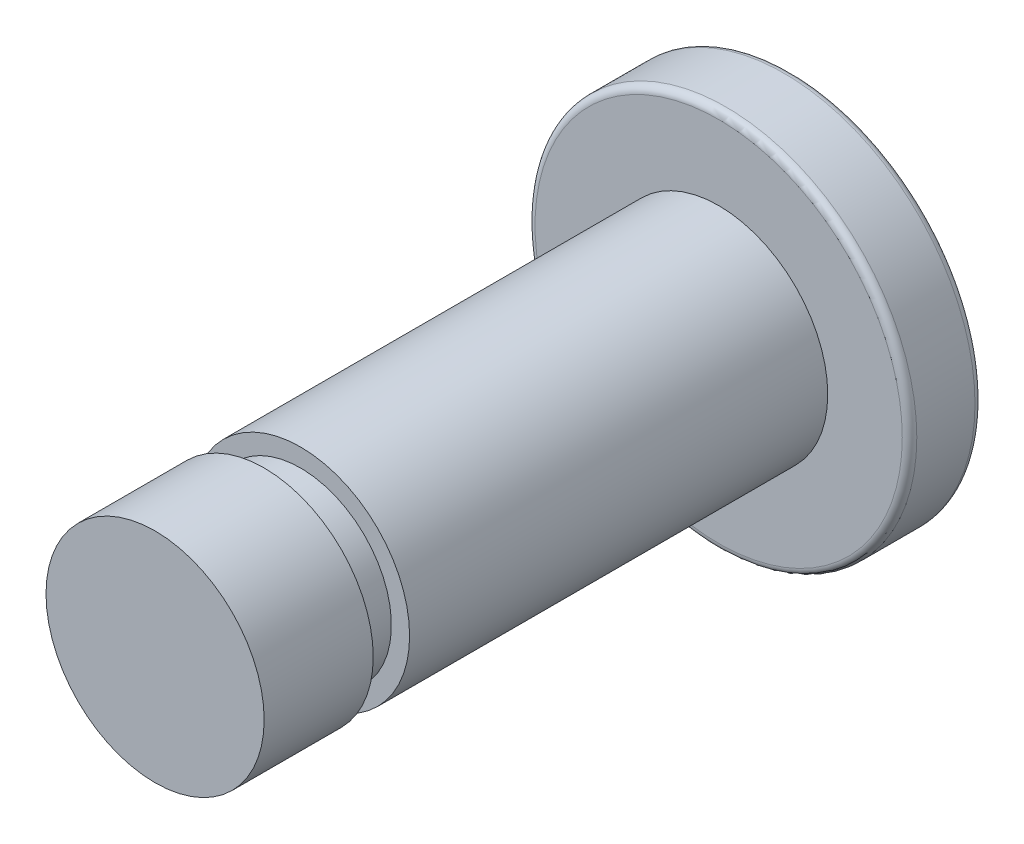
from build123d import *

# Parameters (mm, degrees)
REDONDEO1_R = 0.2


with BuildPart() as part:
    # Croquis2 → Revolución1 (revolve)
    with BuildSketch(Plane(origin=(0, 0, 0), x_dir=(1, 0, 0), z_dir=(0, 1, 0))):
        Polygon((0, 0), (0, 3), (0.5, 3), (0.5, 4), (0, 4), (0, 15.5), (-2.25, 15.5), (-2.25, 17.5), (3, 17.5), (3, 0), align=None)
    revolve(axis=Axis((3, 0, -17.5), (0, 0, 1)))

    # Redondeo1
    redondeo1_edges = [part.edges().sort_by_distance(p)[0] for p in [
        (8.25, 0, -17.5),
        (8.25, 0, -15.5),
    ]]
    fillet(redondeo1_edges, radius=REDONDEO1_R)


solid = part.part
